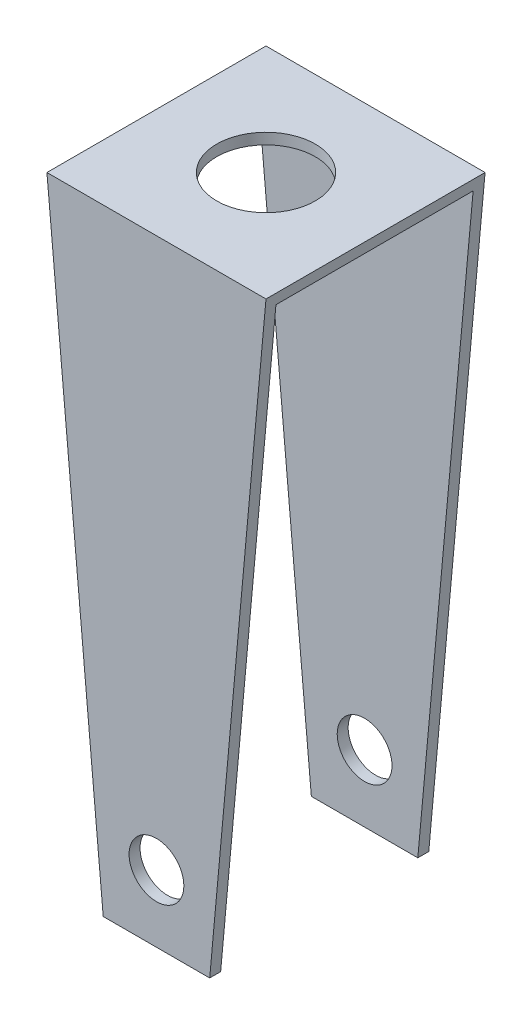
from build123d import *

# Parameters (mm, degrees)
BOSS_EXTRUDE1_DEPTH = 2
CUT_EXTRUDE1_DEPTH  = 2
SKETCH3_R           = 0.25
CUT_EXTRUDE2_DEPTH  = 2
SKETCH4_R           = 0.45
CUT_EXTRUDE3_DEPTH  = 2


with BuildPart() as part:
    # Sketch1 → Boss-Extrude1 (new body)
    with BuildSketch(Plane(origin=(0, 0, 0), x_dir=(0, 0, -1), z_dir=(1, 0, 0))):
        Polygon((-0.9, -2.597609562), (-1, -2.597609562), (-1, 3.027888446), (1, 3.027888446), (1, -2.597609562), (0.9, -2.597609562), (0.9, 2.927888446), (-0.9, 2.927888446), align=None)
    extrude(amount=BOSS_EXTRUDE1_DEPTH)

    # Sketch2 → Cut-Extrude1 (cut)
    with BuildSketch(Plane.XY.offset(1)):
        Polygon((0, 3.027888446), (0.513981797, -2.597609562), (-0.357499118, -2.969117749), (-0.407776863, -2.389247755), align=None)
        Polygon((2.407776863, -2.389247755), (2.357499118, -2.969117749), (1.486018203, -2.597609562), (2, 3.027888446), align=None)
    extrude(amount=-CUT_EXTRUDE1_DEPTH, mode=Mode.SUBTRACT)

    # Sketch3 → Cut-Extrude2 (cut)
    with BuildSketch(Plane.XY.offset(1)):
        with Locations((1, -1.987025794)):
            Circle(SKETCH3_R)
    extrude(amount=-CUT_EXTRUDE2_DEPTH, mode=Mode.SUBTRACT)

    # Sketch4 → Cut-Extrude3 (cut)
    with BuildSketch(Plane(origin=(0, 3.027888446, 0), x_dir=(1, 0, 0), z_dir=(0, 1, 0))):
        with Locations((1, 0)):
            Circle(SKETCH4_R)
    extrude(amount=-CUT_EXTRUDE3_DEPTH, mode=Mode.SUBTRACT)


solid = part.part
